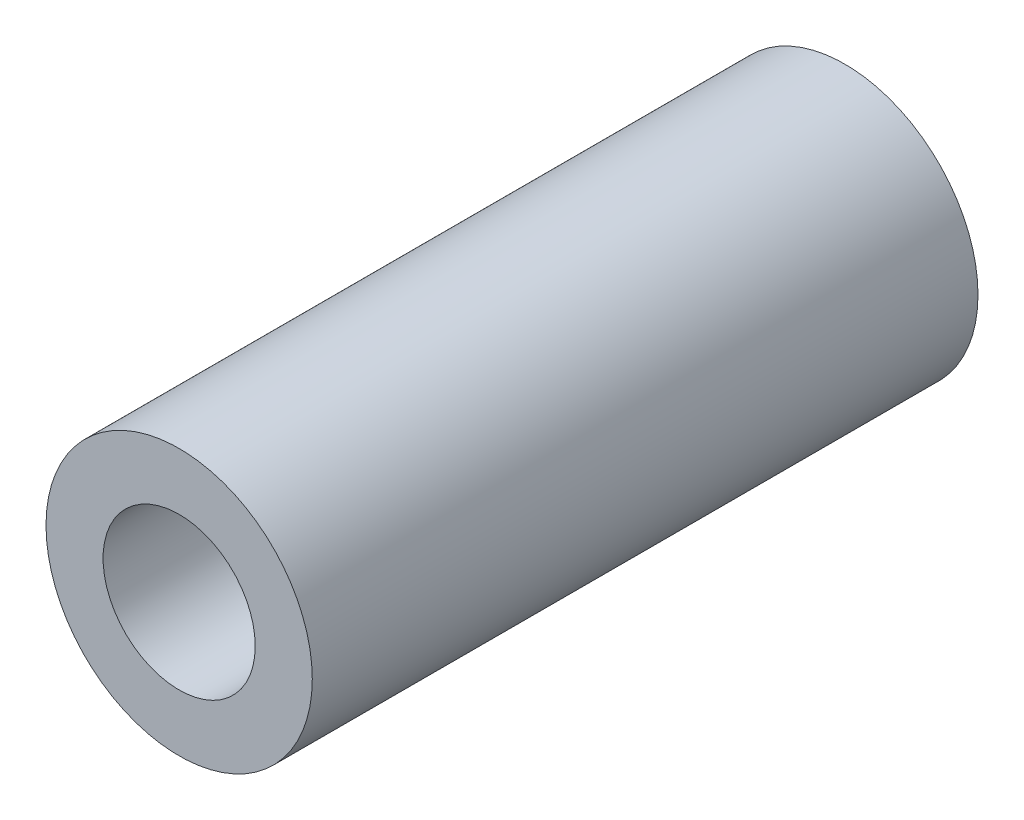
from build123d import *

# Parameters (mm, degrees)
SKETCH1_R           = 7
SKETCH1_R_2         = 4
BOSS_EXTRUDE1_DEPTH = 35


with BuildPart() as part:
    # Sketch1 → Boss-Extrude1 (new body)
    with BuildSketch(Plane.XY):
        Circle(SKETCH1_R)
        Circle(SKETCH1_R_2, mode=Mode.SUBTRACT)
    extrude(amount=BOSS_EXTRUDE1_DEPTH)


solid = part.part
